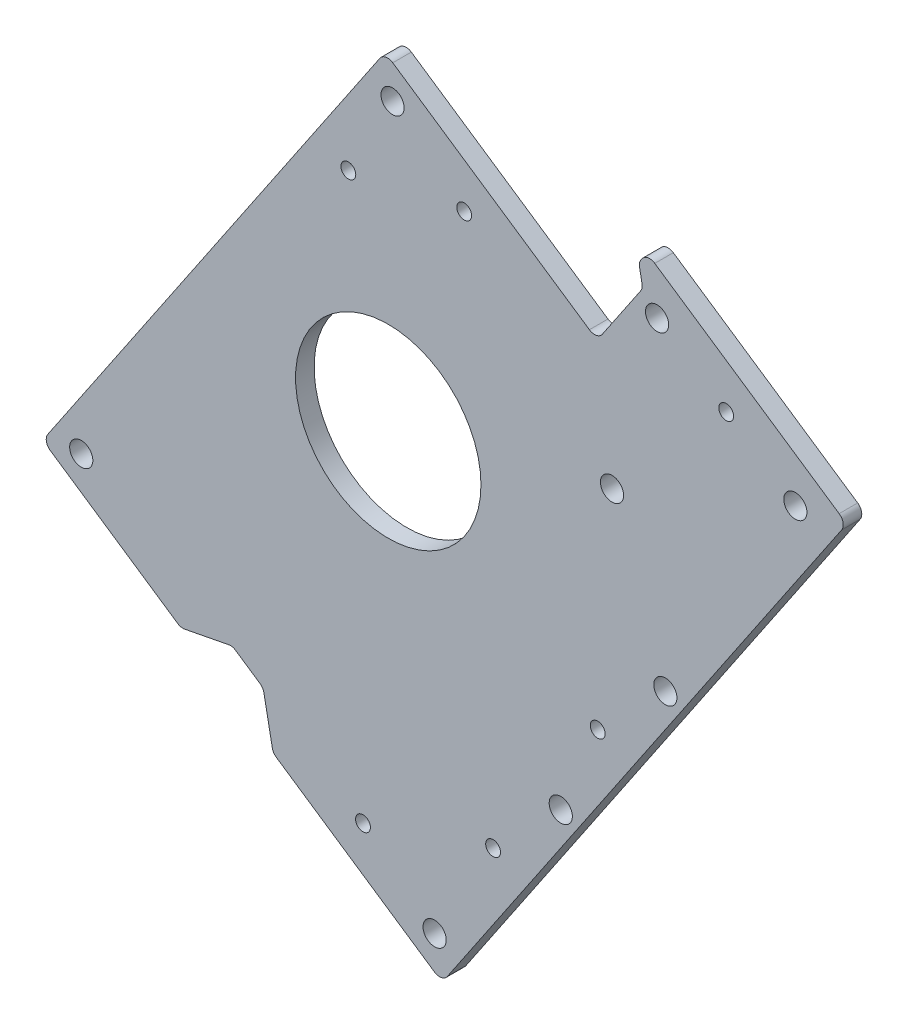
from build123d import *

# Parameters (mm, degrees)
BOSS_EXTRUDE2_DEPTH = 6.35
CUT_EXTRUDE1_DEPTH  = 7.3500001
BOSS_EXTRUDE3_DEPTH = 6.35
SKETCH10_R          = 3.96875
CUT_EXTRUDE2_DEPTH  = 7.35
SKETCH11_R          = 4.5
CUT_EXTRUDE4_DEPTH  = 7.35
BOSS_EXTRUDE4_DEPTH = 6.35
SKETCH13_R          = 3.96875
CUT_EXTRUDE5_DEPTH  = 7.35
LPATTERN1_COUNT     = 2
LPATTERN1_PITCH     = 64
SKETCH14_R          = 2.54
CUT_EXTRUDE6_DEPTH  = 7.35
SKETCH15_R          = 3.96875
CUT_EXTRUDE7_DEPTH  = 7.35
SKETCH16_R          = 3.96875
CUT_EXTRUDE8_DEPTH  = 7.35
SKETCH19_R          = 3.96875
CUT_EXTRUDE11_DEPTH = 7.35
SKETCH21_R          = 2.54
CUT_EXTRUDE12_DEPTH = 7.35
SKETCH22_R          = 31.75
CUT_EXTRUDE13_DEPTH = 7.35
SKETCH23_R          = 5.807663874
SKETCH23_R_2        = 5.610358505
BOSS_EXTRUDE5_DEPTH = 6.35
SKETCH24_R          = 10.761293976
SKETCH24_R_2        = 16.881729782
SKETCH24_R_3        = 7.918988805
BOSS_EXTRUDE6_DEPTH = 6.35
CUT_EXTRUDE14_DEPTH = 7.35
FILLET1_R           = 3.175


with BuildPart() as part:
    # Sketch6 → Boss-Extrude2 (new body)
    with BuildSketch(Plane.XY):
        with BuildLine():
            Line((-68.006850091, -76.67090114), (-109.486767671, -48.656527855))
            Line((-109.486767671, -48.656527855), (-118.371760678, -61.812230963))
            Line((-118.371760678, -61.812230963), (18.447551645, -154.216158235))
            Line((18.447551645, -154.216158235), (135.729459338, 19.43912279))
            Line((135.729459338, 19.43912279), (-1.089852986, 111.843050063))
            Line((-1.089852986, 111.843050063), (-73.946795643, 3.966284577))
            Line((-73.946795643, 3.966284577), (-56.624438948, -7.732749433))
            ThreePointArc((-56.624438948, -7.732749433), (-43.058385537, 37.577891571), (0, 57.15))
            ThreePointArc((0, 57.15), (56.404848571, 31.095576642), (70.829334649, -29.338471048))
            add(Edge.make_bspline(
                [(70.829334649, -29.338471048), (70.811686062, -29.418295928), (70.776015112, -29.578104383), (70.713320217, -29.85478305), (70.619021771, -30.262929245), (70.501052001, -30.762086912), (70.364034474, -31.322191481), (70.199318515, -31.970958926), (70.000453855, -32.723919765), (69.795103485, -33.469783355), (69.582015398, -34.214296028), (69.361377803, -34.956693289), (69.133257682, -35.696762218), (68.838782679, -36.61892651), (68.470566207, -37.720710028), (68.019498024, -38.998776477), (67.474836154, -40.448808619), (66.901337925, -41.887676852), (66.299328392, -43.31485223), (65.669141732, -44.729810424), (65.011119088, -46.132040323), (64.325609411, -47.52103904), (63.612968547, -48.896314904), (62.87355937, -50.257385735), (62.107751613, -51.603779381), (61.315921169, -52.935034173), (60.49845004, -54.250698756), (59.655726138, -55.550331897), (58.571247582, -57.154294757), (57.220953058, -59.045283389), (55.576035723, -61.200397094), (53.604026134, -63.590264702), (51.54329346, -65.904053004), (49.39728314, -68.138962994), (47.169496434, -70.29235602), (44.863486103, -72.361752995), (42.482847363, -74.344831806), (40.031215607, -76.239428526), (36.882516177, -78.494556171), (32.976808929, -81.016011003), (28.250788286, -83.68089187), (21.41551215, -86.919136497), (14.30829026, -89.526654921), (6.996956895, -91.488176442), (-0.451922312, -92.797413176), (-6.61686174, -93.456358442), (-12.81195397, -93.702029749), (-19.009644204, -93.537285056), (-25.183124422, -92.966685286), (-31.306438312, -91.996382122), (-36.598524037, -90.804323442), (-41.072542301, -89.543185606), (-44.752319298, -88.33589156), (-47.664184976, -87.27761875), (-50.541347258, -86.128353728), (-53.381128552, -84.889612663), (-56.180924218, -83.562977818), (-58.593536599, -82.326710176), (-60.633378351, -81.214215821), (-62.313751085, -80.252471782), (-63.646071553, -79.462491566), (-64.966093336, -78.652178853), (-66.222359154, -77.854259082), (-67.143044791, -77.250601571), (-67.736251212, -76.85365602), (-68.006850091, -76.67090114)],
                knots=[0.071020771, 0.071020771, 0.071020771, 0.071020771, 0.071020771, 0.072848477, 0.074676184, 0.07650389, 0.078331597, 0.08198701, 0.085642423, 0.089297836, 0.092953249, 0.096608662, 0.100264075, 0.103919488, 0.107574901, 0.114885727, 0.122196554, 0.12950738, 0.136818214, 0.144129048, 0.151439882, 0.158750716, 0.166061558, 0.173372401, 0.180683243, 0.187994085, 0.195304924, 0.202615763, 0.209926602, 0.217237441, 0.231859103, 0.246480766, 0.261102426, 0.275724085, 0.290345754, 0.304967424, 0.319589099, 0.334210774, 0.348832457, 0.36345414, 0.392697464, 0.421940789, 0.451184112, 0.506140643, 0.535383973, 0.564627303, 0.593870641, 0.623113979, 0.652357319, 0.68160066, 0.710843985, 0.740087309, 0.754708984, 0.769330659, 0.783952333, 0.798574008, 0.813195669, 0.82781733, 0.842438991, 0.849749821, 0.857060652, 0.86437149, 0.871682327, 0.878993165, 0.885158103, 0.885158103, 0.885158103, 0.885158103, 0.885158103], degree=4))
        make_face()
    extrude(amount=BOSS_EXTRUDE2_DEPTH)

    # Sketch8 → Cut-Extrude1 (cut, through all)
    with BuildSketch(Plane.XY.offset(6.35)):
        Polygon((-71.011229489, -93.798205788), (-53.378672597, -90.381637707), (-42.854110111, -97.489632113), (-39.43754203, -115.122189004), align=None)
    extrude(amount=-CUT_EXTRUDE1_DEPTH, mode=Mode.SUBTRACT)

    # Sketch9 → Boss-Extrude3 (add, through all)
    with BuildSketch(Plane.XY.offset(6.35)):
        Polygon((-1.089852986, 111.843050063), (-109.486767671, -48.656527855), (27.332544652, -141.060455127), (135.729459338, 19.43912279), align=None)
    extrude(amount=-BOSS_EXTRUDE3_DEPTH)

    # Sketch10 → Cut-Extrude2 (cut, through all)
    with BuildSketch(Plane.XY.offset(6.35)):
        with Locations((4.996496209, -84.796642912)):
            Circle(SKETCH10_R)
        with Locations((40.816310536, -31.759477627)):
            Circle(SKETCH10_R)
        with Locations((76.636124864, 21.277687659)):
            Circle(SKETCH10_R)
        with Locations((-45.295165913, -45.214466102)):
            Circle(SKETCH10_R)
    extrude(amount=-CUT_EXTRUDE2_DEPTH, mode=Mode.SUBTRACT)

    # Sketch11 → Cut-Extrude4 (cut, through all)
    with BuildSketch(Plane.XY.offset(6.35)):
        Circle(SKETCH11_R)
    extrude(amount=-CUT_EXTRUDE4_DEPTH, mode=Mode.SUBTRACT)

    # Sketch12 → Boss-Extrude4 (add, through all)
    with BuildSketch(Plane.XY.offset(6.35)):
        Polygon((135.729459338, 19.43912279), (67.319803176, 65.641086427), (88.643786393, 97.214773886), (157.053442554, 51.01281025), align=None)
    extrude(amount=-BOSS_EXTRUDE4_DEPTH)

    # Sketch13 → Cut-Extrude5 (cut, through all)
    with BuildSketch(Plane.XY.offset(6.35)):
        with Locations((94.899221836, -29.671127724)):
            Circle(SKETCH13_R)
    cut_extrude5 = extrude(amount=-CUT_EXTRUDE5_DEPTH, mode=Mode.SUBTRACT)

    # LPattern1: Cut-Extrude5 ×2
    with Locations(*[Vector(-0.559684599, -0.828705708, 0) * (i * LPATTERN1_PITCH) for i in range(1, LPATTERN1_COUNT)]):
        add(cut_extrude5, mode=Mode.SUBTRACT)

    # Sketch14 → Cut-Extrude6 (cut, through all)
    with BuildSketch(Plane.XY.offset(6.35)):
        with Locations((71.72703343, -52.635713164)):
            Circle(SKETCH14_R)
        with Locations((35.907219102, -105.67287845)):
            Circle(SKETCH14_R)
        with Locations((115.740620068, 63.589229581)):
            Circle(SKETCH14_R)
    extrude(amount=-CUT_EXTRUDE6_DEPTH, mode=Mode.SUBTRACT)

    # Sketch15 → Cut-Extrude7 (cut, through all)
    with BuildSketch(Plane.XY.offset(6.35)):
        with Locations((-105.147343009, -59.249804902)):
            Circle(SKETCH15_R)
        with Locations((15.885125585, -140.991740566)):
            Circle(SKETCH15_R)
        with Locations((1.472573075, 98.618632394)):
            Circle(SKETCH15_R)
    extrude(amount=-CUT_EXTRUDE7_DEPTH, mode=Mode.SUBTRACT)

    # Sketch16 → Cut-Extrude8 (cut, through all)
    with BuildSketch(Plane.XY.offset(6.35)):
        with Locations((92.060354474, 79.582216994)):
            Circle(SKETCH16_R)
        with Locations((139.420885662, 47.596242169)):
            Circle(SKETCH16_R)
    extrude(amount=-CUT_EXTRUDE8_DEPTH, mode=Mode.SUBTRACT)

    # Sketch19 → Cut-Extrude11 (cut, through all)
    with BuildSketch(Plane.XY.offset(6.35)):
        with Locations((-65.680233685, -85.904783923)):
            Circle(SKETCH19_R)
    extrude(amount=-CUT_EXTRUDE11_DEPTH, mode=Mode.SUBTRACT)

    # Sketch21 → Cut-Extrude12 (cut, through all)
    with BuildSketch(Plane.XY.offset(6.35)):
        with Locations((-13.666272317, 70.530227577)):
            Circle(SKETCH21_R)
        with Locations((26.00698069, 78.217505758)):
            Circle(SKETCH21_R)
        with Locations((-86.729358658, -71.688795112)):
            Circle(SKETCH21_R)
        with Locations((-8.64928203, -120.590613931)):
            Circle(SKETCH21_R)
    extrude(amount=-CUT_EXTRUDE12_DEPTH, mode=Mode.SUBTRACT)

    # Sketch22 → Cut-Extrude13 (cut, through all)
    with BuildSketch(Plane.XY.offset(6.35)):
        Circle(SKETCH22_R)
    extrude(amount=-CUT_EXTRUDE13_DEPTH, mode=Mode.SUBTRACT)

    # Sketch23 → Boss-Extrude5 (add, through all)
    with BuildSketch(Plane.XY.offset(6.35)):
        with Locations((-65.680233685, -85.904783923)):
            Circle(SKETCH23_R)
        with Locations((-86.729358658, -71.688795112)):
            Circle(SKETCH23_R_2)
    extrude(amount=-BOSS_EXTRUDE5_DEPTH)

    # Sketch24 → Boss-Extrude6 (add, through all)
    with BuildSketch(Plane.XY.offset(6.35)):
        with Locations((-45.295165913, -45.214466102)):
            Circle(SKETCH24_R)
        with Locations((4.996496209, -84.796642912)):
            Circle(SKETCH24_R_2)
        with Locations((40.816310536, -31.759477627)):
            Circle(SKETCH24_R_3)
    extrude(amount=-BOSS_EXTRUDE6_DEPTH)

    # Sketch25 → Cut-Extrude14 (cut, through all)
    with BuildSketch(Plane.XY.offset(6.35)):
        Polygon((85.800588631, 93.004948891), (87.167215863, 85.951926135), (71.529628171, 62.797888664), (67.319803176, 65.641086427), align=None)
    extrude(amount=-CUT_EXTRUDE14_DEPTH, mode=Mode.SUBTRACT)

    # Fillet1
    fillet1_edges = [part.edges().sort_by_distance(p)[0] for p in [
        (-1.089852986, 111.843050063, 3.175),
        (18.447551645, -154.216158235, 3.175),
        (-118.371760678, -61.812230963, 3.175),
        (85.800588631, 93.004948891, 3.175),
        (87.167215863, 85.951926135, 3.175),
        (71.529628171, 62.797888664, 3.175),
        (-39.43754203, -115.122189004, 3.175),
        (-71.011229489, -93.798205788, 3.175),
        (-53.378672597, -90.381637707, 3.175),
        (-42.854110111, -97.489632113, 3.175),
        (157.053442554, 51.01281025, 3.175),
        (88.643786393, 97.214773886, 3.175),
    ]]
    fillet(fillet1_edges, radius=FILLET1_R)


solid = part.part
